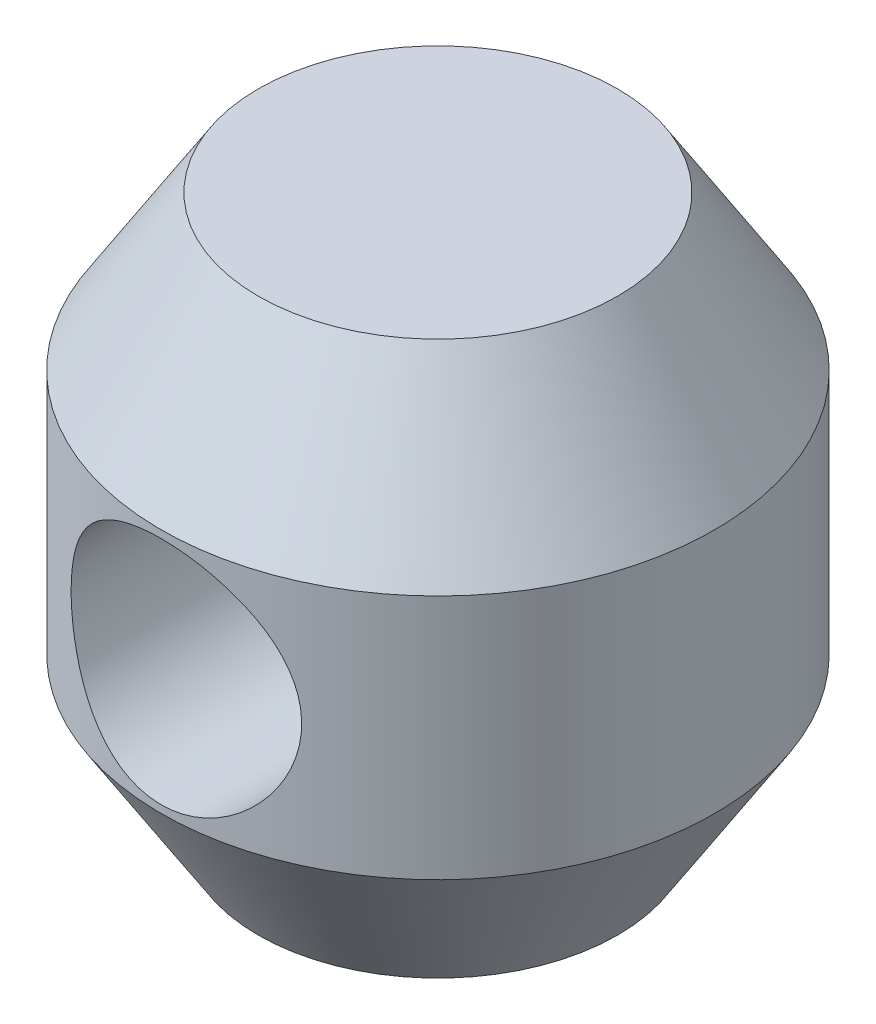
from build123d import *

# Parameters (mm, degrees)
SKETCH3_R               = 3.96875
CUT_EXTRUDE1_DEPTH      = 10.525
CUT_EXTRUDE1_DEPTH_BACK = 10.525


with BuildPart() as part:
    # Sketch1 → Revolve1 (revolve)
    with BuildSketch(Plane.XY):
        Polygon((0, 9.525), (0, -9.525), (6.184280622, -9.525), (9.525, -4.229561572), (9.525, 4.229561572), (6.184280622, 9.525), align=None)
    revolve(axis=Axis((0, 20.829425287, 0), (0, -1, 0)))

    # Sketch3 → Cut-Extrude1 (cut, two sides)
    with BuildSketch(Plane(origin=(0, 9.525, 0), x_dir=(0, 1, 0), z_dir=(0, 0, -1))) as cut_extrude1_sk:
        with Locations((-9.525, 0)):
            Circle(SKETCH3_R)
    extrude(amount=CUT_EXTRUDE1_DEPTH, mode=Mode.SUBTRACT)
    extrude(cut_extrude1_sk.sketch, amount=-CUT_EXTRUDE1_DEPTH_BACK, mode=Mode.SUBTRACT)


solid = part.part
